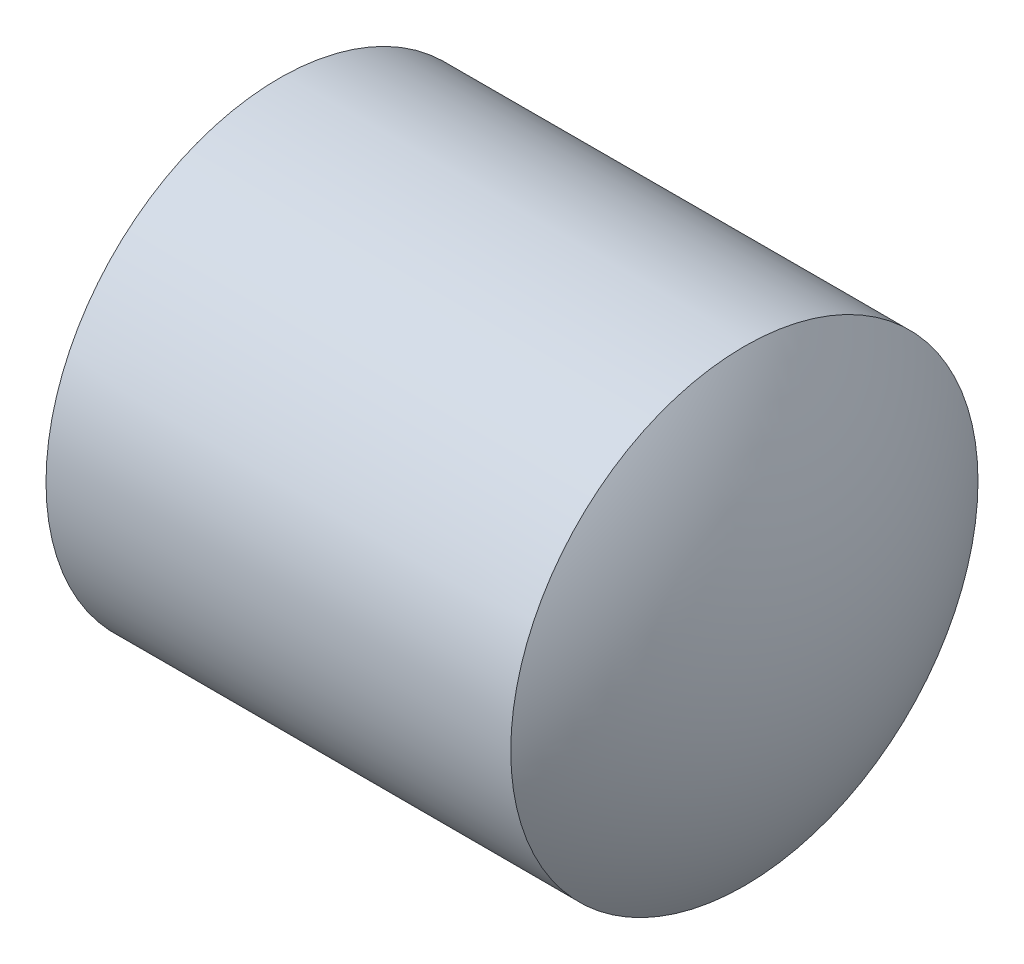
from build123d import *


with BuildPart() as part:
    # Sketch1 → Revolve9 (revolve)
    with BuildSketch(Plane(origin=(0, 0, 0), x_dir=(1, 0, 0), z_dir=(0, 1, 0))):
        with BuildLine():
            Line((-0.319470256, 260.598664702), (0.682096548, 260))
            Line((0.682096548, 260), (259.317903452, 260))
            ThreePointArc((259.317903452, 260), (289.90804135, 198.17314503), (300.431293161, 130))
            Line((300.431293161, 130), (301.431293161, 130))
            ThreePointArc((301.431293161, 130), (290.825477923, 198.588466156), (259.998700011, 260.770222081))
            Line((259.998700011, 260.770222081), (-0.319470256, 260.598664702))
        make_face()
    revolve(axis=Axis((61.504845389, 0, -130), (1, 0, 0)))


solid = part.part
